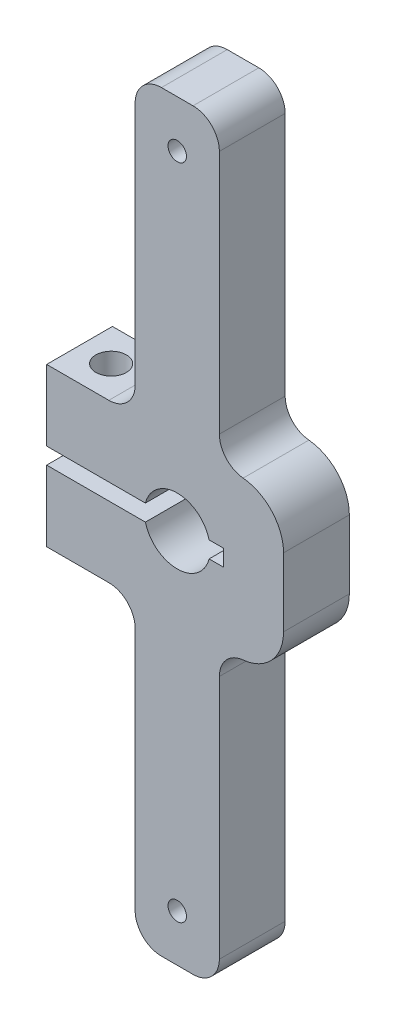
from build123d import *

# Parameters (mm, degrees)
EXTRUDE1_DEPTH              = 6.35
SKETCH2_W                   = 17.047492734
SKETCH2_H                   = 1.5875
EXTRUDE2_DEPTH              = 7.35
SKETCH4_R                   = 3.175
EXTRUDE4_DEPTH              = 7.35
FILLET2_R                   = 4.318
F_32_0_116_DIAMETER_HOLE1_D = 2.9464
EXTRUDE8_DEPTH              = 28.6766
FILLET1_R                   = 2.54


with BuildPart() as part:
    # Sketch1 → Extrude1 (new body)
    with BuildSketch(Plane.XY):
        Polygon((-21.492492734, 7.62), (-6.252492734, 7.62), (1.367507266, 7.62), (1.367507266, 0), (1.367507266, -7.62), (-6.252492734, -7.62), (-21.492492734, -7.62), align=None)
    extrude(amount=EXTRUDE1_DEPTH)

    # Sketch2 → Extrude2 (cut, through all)
    with BuildSketch(Plane.XY.offset(6.35)):
        with Locations((-12.968746367, 0)):
            Rectangle(SKETCH2_W, SKETCH2_H)
    extrude(amount=-EXTRUDE2_DEPTH, mode=Mode.SUBTRACT)

    # Sketch4 → Extrude4 (cut, through all)
    with BuildSketch(Plane.XY.offset(6.35)):
        with Locations((-8.89, 0)):
            Circle(SKETCH4_R)
    extrude(amount=-EXTRUDE4_DEPTH, mode=Mode.SUBTRACT)

    # Fillet2
    fillet2_edges = [part.edges().sort_by_distance(p)[0] for p in [
        (1.367507266, 7.62, 3.175),
        (1.367507266, -7.62, 3.175),
    ]]
    fillet(fillet2_edges, radius=FILLET2_R)

    # #32 (0.116) Diameter Hole1 (through all)
    with Locations(Plane(origin=(-18.444492734, -7.62, 3.175), x_dir=(0, 0, -1), z_dir=(0, -1, 0))):
        with Locations((0, 0)):
            Hole(F_32_0_116_DIAMETER_HOLE1_D / 2)

    # Sketch21 → Extrude8 (add)
    with BuildSketch(Plane(origin=(0, 7.62, 0), x_dir=(1, 0, 0), z_dir=(0, 1, 0))):
        Polygon((-8.89, 0), (-4.826, 0), (-4.826, -6.35), (-12.954, -6.35), (-12.954, 0), align=None)
    extrude8 = extrude(amount=EXTRUDE8_DEPTH)

    # Sketch27 → #50 (0.07) Diameter Hole1 (revolve, cut)
    with BuildSketch(Plane(origin=(-8.89, 31.75, 0), x_dir=(0, 1, 0), z_dir=(1, 0, 0))):
        Polygon((0, 0), (0, 6.88416509), (0.889, 6.35), (0.889, 0), align=None)
    f_50_0_07_diameter_hole1 = revolve(axis=Axis((-8.89, 31.75, -6.35), (0, 0, 1)), mode=Mode.SUBTRACT)

    # Mirror2: Extrude8, #50 (0.07) Diameter Hole1 across plane
    add(extrude8.mirror(Plane.ZX))
    add(f_50_0_07_diameter_hole1.mirror(Plane.ZX), mode=Mode.SUBTRACT)

    # Fillet1
    fillet1_edges = [part.edges().sort_by_distance(p)[0] for p in [
        (-12.954, 7.62, 3.175),
        (-4.826, 7.62, 3.175),
        (-12.954, 36.2966, 3.175),
        (-4.826, 36.2966, 3.175),
        (-12.954, -36.2966, 3.175),
        (-12.954, -7.62, 3.175),
        (-4.826, -7.62, 3.175),
        (-4.826, -36.2966, 3.175),
    ]]
    fillet(fillet1_edges, radius=FILLET1_R)


solid = part.part
